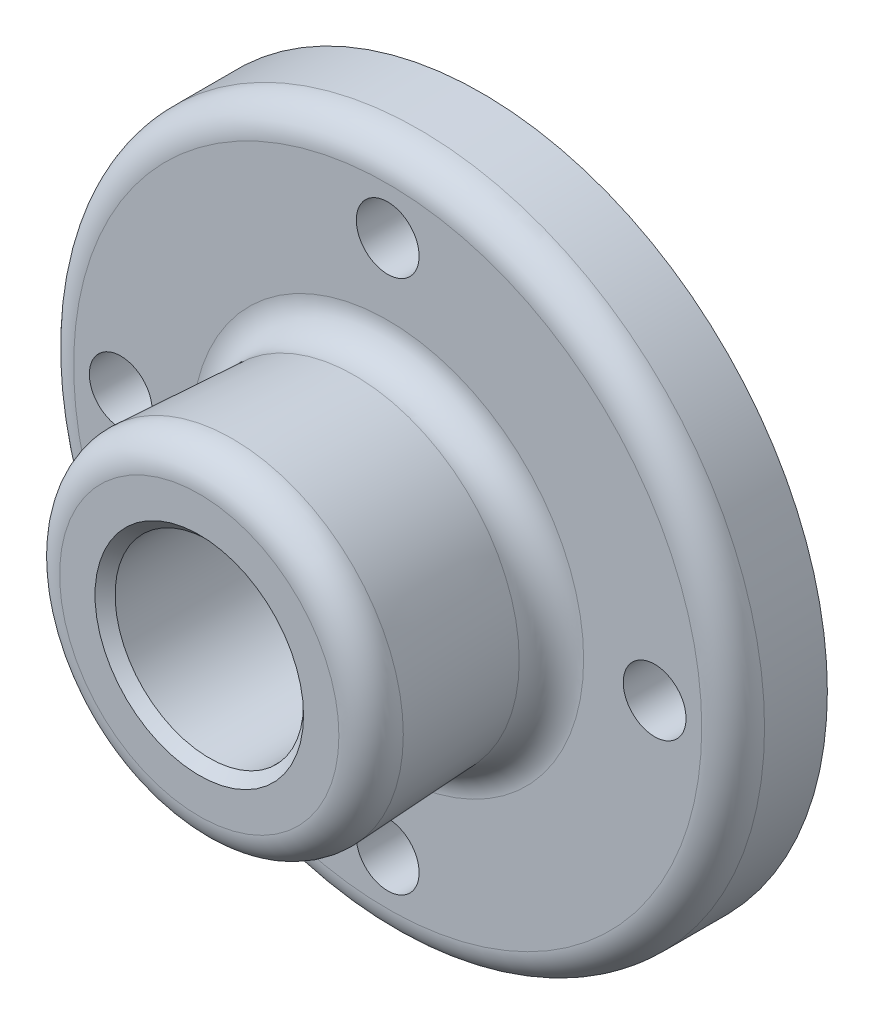
from build123d import *

# Parameters (mm, degrees)
SKETCH1_R           = 69.85
BOSS_EXTRUDE1_DEPTH = 19.05
SKETCH3_R           = 34.925
BOSS_EXTRUDE2_DEPTH = 38.1
BOSS_EXTRUDE2_TAPER = 3
SKETCH4_R           = 19.05
CUT_EXTRUDE1_DEPTH  = 20.05
SKETCH5_R           = 19.05
BOLT_HOLE_DEPTH     = 58.15
SKETCH6_R           = 6.35
CUT_EXTRUDE3_DEPTH  = 20.05
CIRPATTERN2_COUNT   = 4
FILLET1_R           = 6.35
CHAMFER1_SIZE       = 2.032


with BuildPart() as part:
    # Sketch1 → Boss-Extrude1 (new body)
    with BuildSketch(Plane.XY):
        Circle(SKETCH1_R)
    extrude(amount=BOSS_EXTRUDE1_DEPTH)

    # Sketch3 → Boss-Extrude2 (add)
    with BuildSketch(Plane.XY.offset(57.15)):
        Circle(SKETCH3_R)
    extrude(amount=-BOSS_EXTRUDE2_DEPTH, taper=BOSS_EXTRUDE2_TAPER)

    # Sketch4 → Cut-Extrude1 (cut, through all)
    with BuildSketch(Plane.XY.offset(19.05)):
        Circle(SKETCH4_R)
    extrude(amount=-CUT_EXTRUDE1_DEPTH, mode=Mode.SUBTRACT)

    # Sketch5 → Bolt Hole (cut, through all)
    with BuildSketch(Plane.XY.offset(57.15)):
        Circle(SKETCH5_R)
    extrude(amount=-BOLT_HOLE_DEPTH, mode=Mode.SUBTRACT)

    # Sketch6 → Cut-Extrude3 (cut, through all)
    with BuildSketch(Plane.XY.offset(19.05)):
        with Locations((0, 53.975)):
            Circle(SKETCH6_R)
    cut_extrude3 = extrude(amount=-CUT_EXTRUDE3_DEPTH, mode=Mode.SUBTRACT)

    # CirPattern2: Cut-Extrude3 ×4 about axis
    cirpattern2_axis = Axis((0, 0, 0), (0, 0, 1))
    for i in range(1, CIRPATTERN2_COUNT):
        add(cut_extrude3.rotate(cirpattern2_axis, i * 360 / CIRPATTERN2_COUNT), mode=Mode.SUBTRACT)

    # Fillet1
    fillet1_edges = [part.edges().sort_by_distance(p)[0] for p in [
        (-69.85, 0, 19.05),
        (-34.925, 0, 57.15),
        (-32.928263609, 0, 19.05),
    ]]
    fillet(fillet1_edges, radius=FILLET1_R)

    # Chamfer1
    chamfer1_edges = [part.edges().sort_by_distance(p)[0] for p in [
        (-19.05, 0, 57.15),
    ]]
    chamfer(chamfer1_edges, length=CHAMFER1_SIZE)


solid = part.part
